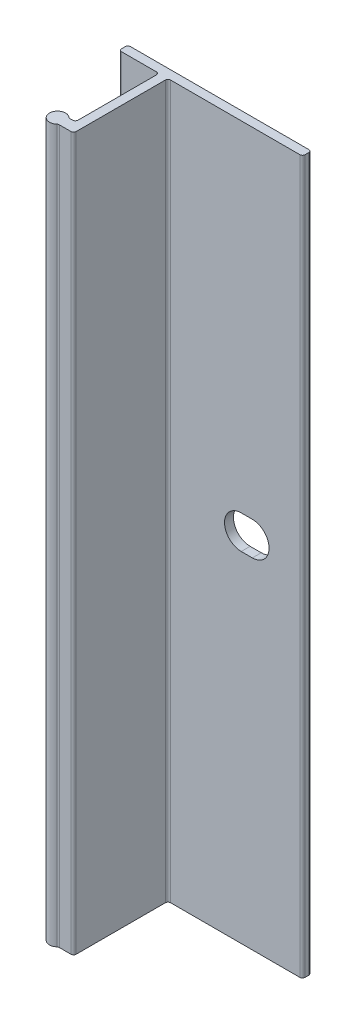
from build123d import *

# Parameters (mm, degrees)
BOSS_EXTRUDE1_DEPTH = 50.8
CUT_EXTRUDE1_DEPTH  = 2.27


with BuildPart() as part:
    # Sketch2 → Boss-Extrude1 (new body, symmetric)
    with BuildSketch(Plane(origin=(0, 0, 0), x_dir=(1, 0, 0), z_dir=(0, 1, 0))):
        with BuildLine():
            Line((-5.334, 0), (20.066, 0))
            ThreePointArc((20.066, 0), (20.335407684, -0.111592316), (20.447, -0.381))
            Line((20.447, -0.381), (20.447, -0.889))
            ThreePointArc((20.447, -0.889), (20.335407684, -1.158407684), (20.066, -1.27))
            Line((20.066, -1.27), (1.651, -1.27))
            ThreePointArc((1.651, -1.27), (1.381592316, -1.381592316), (1.27, -1.651))
            Line((1.27, -1.651), (1.27, -14.351))
            ThreePointArc((1.27, -14.351), (1.158407684, -14.620407684), (0.889, -14.732))
            Line((0.889, -14.732), (-0.76996875, -14.732))
            ThreePointArc((-0.76996875, -14.732), (-0.904672592, -14.756607134), (-1.021976563, -14.82725))
            ThreePointArc((-1.021976563, -14.82725), (-2.921, -13.97), (-1.021976563, -13.11275))
            ThreePointArc((-1.021976563, -13.11275), (-0.904672592, -13.183392866), (-0.76996875, -13.208))
            Line((-0.76996875, -13.208), (-0.381, -13.208))
            ThreePointArc((-0.381, -13.208), (-0.111592316, -13.096407684), (0, -12.827))
            Line((0, -12.827), (0, -1.651))
            ThreePointArc((0, -1.651), (-0.111592316, -1.381592316), (-0.381, -1.27))
            Line((-0.381, -1.27), (-5.334, -1.27))
            ThreePointArc((-5.334, -1.27), (-5.603407684, -1.158407684), (-5.715, -0.889))
            Line((-5.715, -0.889), (-5.715, -0.381))
            ThreePointArc((-5.715, -0.381), (-5.603407684, -0.111592316), (-5.334, 0))
        make_face()
    extrude(amount=BOSS_EXTRUDE1_DEPTH, both=True)

    # Sketch3 → Cut-Extrude1 (cut, through all)
    with BuildSketch(Plane.XY.offset(1.27)):
        with BuildLine():
            Line((11.71575, 2.38125), (13.30325, 2.38125))
            ThreePointArc((13.30325, 2.38125), (15.6845, 0), (13.30325, -2.38125))
            Line((13.30325, -2.38125), (11.71575, -2.38125))
            ThreePointArc((11.71575, -2.38125), (9.3345, 0), (11.71575, 2.38125))
        make_face()
    extrude(amount=-CUT_EXTRUDE1_DEPTH, mode=Mode.SUBTRACT)


solid = part.part
